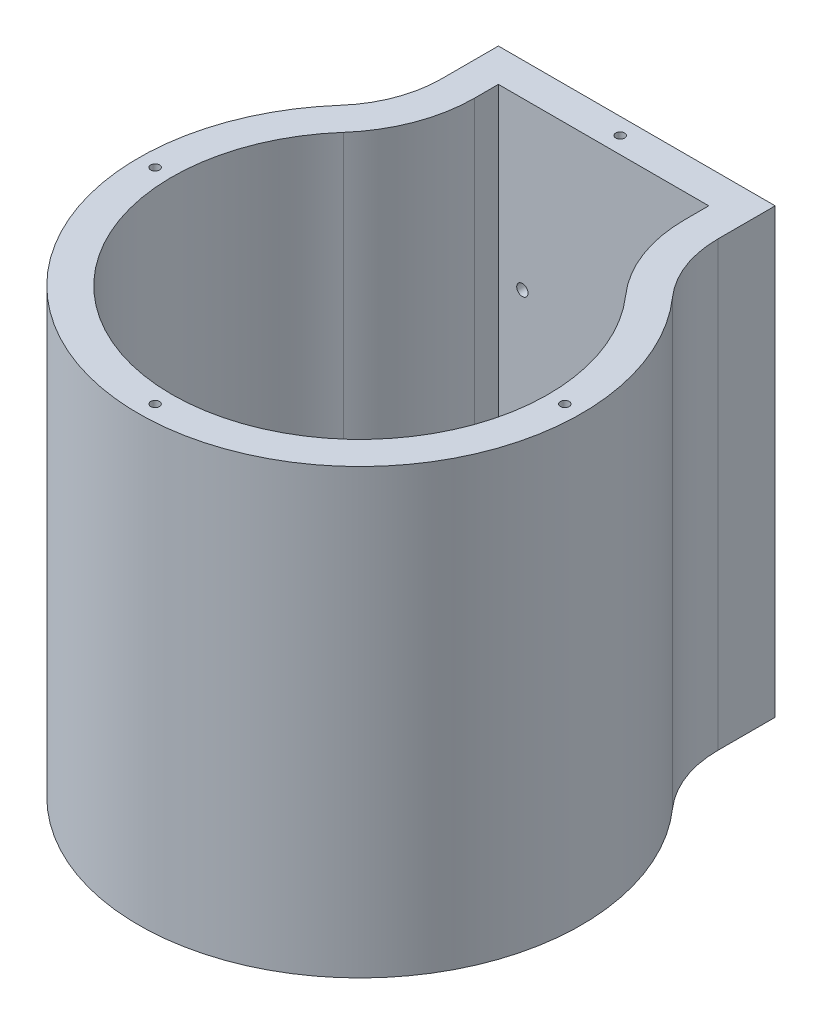
from build123d import *

# Parameters (mm, degrees)
EXTRUDE_1_DEPTH               = 80
CUT_EXTRUDE_1_DEPTH           = 74
HOLE_WIZARD_2_05_2_05_1_D     = 2.05
HOLE_WIZARD_2_05_2_05_1_DEPTH = 6
HOLE_WIZARD_1_6_1_6_1_D       = 1.6
HOLE_WIZARD_1_6_1_6_1_DEPTH   = 5.2
HOLE_WIZARD_1_6_1_6_1_TIP     = 0.480688495
HOLE_WIZARD_M2_1_D            = 2.4
HOLE_WIZARD_M2_1_DEPTH        = 6
HOLE_WIZARD_M2_1_CBORE_D      = 4.5
HOLE_WIZARD_M2_1_CBORE_DEPTH  = 2
HOLE_WIZARD_1_D               = 5
HOLE_WIZARD_1_DEPTH           = 80
HOLE_WIZARD_1_CBORE_D         = 11
HOLE_WIZARD_1_CBORE_DEPTH     = 2.2
FILLET_1_R                    = 20
FILLET_2_R                    = 26


with BuildPart() as part:
    # 스케치1 → 보스-돌출1 (new body)
    with BuildSketch(Plane.XZ):
        with BuildLine():
            Line((-25, -31.224989992), (-25, -50))
            Line((-25, -50), (25, -50))
            Line((25, -50), (25, -31.224989992))
            ThreePointArc((25, -31.224989992), (0, 40), (-25, -31.224989992))
        make_face()
    extrude(amount=-EXTRUDE_1_DEPTH)

    # 스케치2 → 컷-돌출1 (cut)
    with BuildSketch(Plane(origin=(0, 80, 0), x_dir=(-1, 0, 0), z_dir=(0, 1, 0))):
        with BuildLine():
            Line((-19, -44), (19, -44))
            Line((19, -44), (19, -28.19574436))
            ThreePointArc((19, -28.19574436), (0, 34), (-19, -28.19574436))
            Line((-19, -28.19574436), (-19, -44))
        make_face()
    extrude(amount=-CUT_EXTRUDE_1_DEPTH, mode=Mode.SUBTRACT)

    # Ø2.05 (2.05) 지름 구멍1
    with Locations(Plane(origin=(0, 0, -50), x_dir=(-1, 0, 0), z_dir=(0, 0, -1))):
        with Locations((-14.666776399, 50), (-14.666776399, 30), (14.666776399, 50), (14.666776399, 30)):
            Hole(HOLE_WIZARD_2_05_2_05_1_D / 2, depth=HOLE_WIZARD_2_05_2_05_1_DEPTH)

    # Ø1.6 (1.6) 지름 구멍1
    with Locations(Plane(origin=(0, 80, 0), x_dir=(1, 0, 0), z_dir=(0, 1, 0))):
        with Locations((0, 47), (-37, 0), (37, 0), (0, -37)):
            Hole(HOLE_WIZARD_1_6_1_6_1_D / 2, depth=HOLE_WIZARD_1_6_1_6_1_DEPTH)
            with Locations((0, 0, -(HOLE_WIZARD_1_6_1_6_1_DEPTH + HOLE_WIZARD_1_6_1_6_1_TIP / 2))):  # 118° drill point
                Cone(0, HOLE_WIZARD_1_6_1_6_1_D / 2, HOLE_WIZARD_1_6_1_6_1_TIP, mode=Mode.SUBTRACT)

    # M2 육각 머리 작은 나사용 카운터보어1
    with Locations(Plane(origin=(0, 6, 0), x_dir=(1, 0, 0), z_dir=(0, 1, 0))):
        with Locations((0, 8), (5.656854249, 5.656854249), (8, 0), (5.656854249, -5.656854249), (0, -8), (-5.656854249, -5.656854249), (-8, 0), (-5.656854249, 5.656854249)):
            CounterBoreHole(HOLE_WIZARD_M2_1_D / 2, HOLE_WIZARD_M2_1_CBORE_D / 2, HOLE_WIZARD_M2_1_CBORE_DEPTH, depth=HOLE_WIZARD_M2_1_DEPTH)

    # 구멍1
    with Locations(Plane(origin=(0, 0, 0), x_dir=(-1, 0, 0), z_dir=(0, -1, 0))):
        with Locations((0, 0)):
            CounterBoreHole(HOLE_WIZARD_1_D / 2, HOLE_WIZARD_1_CBORE_D / 2, HOLE_WIZARD_1_CBORE_DEPTH, depth=HOLE_WIZARD_1_DEPTH)

    # 필렛1
    fillet_1_edges = [part.edges().sort_by_distance(p)[0] for p in [
        (25, 40, -31.224989992),
        (-25, 40, -31.224989992),
    ]]
    fillet(fillet_1_edges, radius=FILLET_1_R)

    # 필렛2
    fillet_2_edges = [part.edges().sort_by_distance(p)[0] for p in [
        (19, 43, -28.19574436),
        (-19, 43, -28.19574436),
    ]]
    fillet(fillet_2_edges, radius=FILLET_2_R)


solid = part.part
